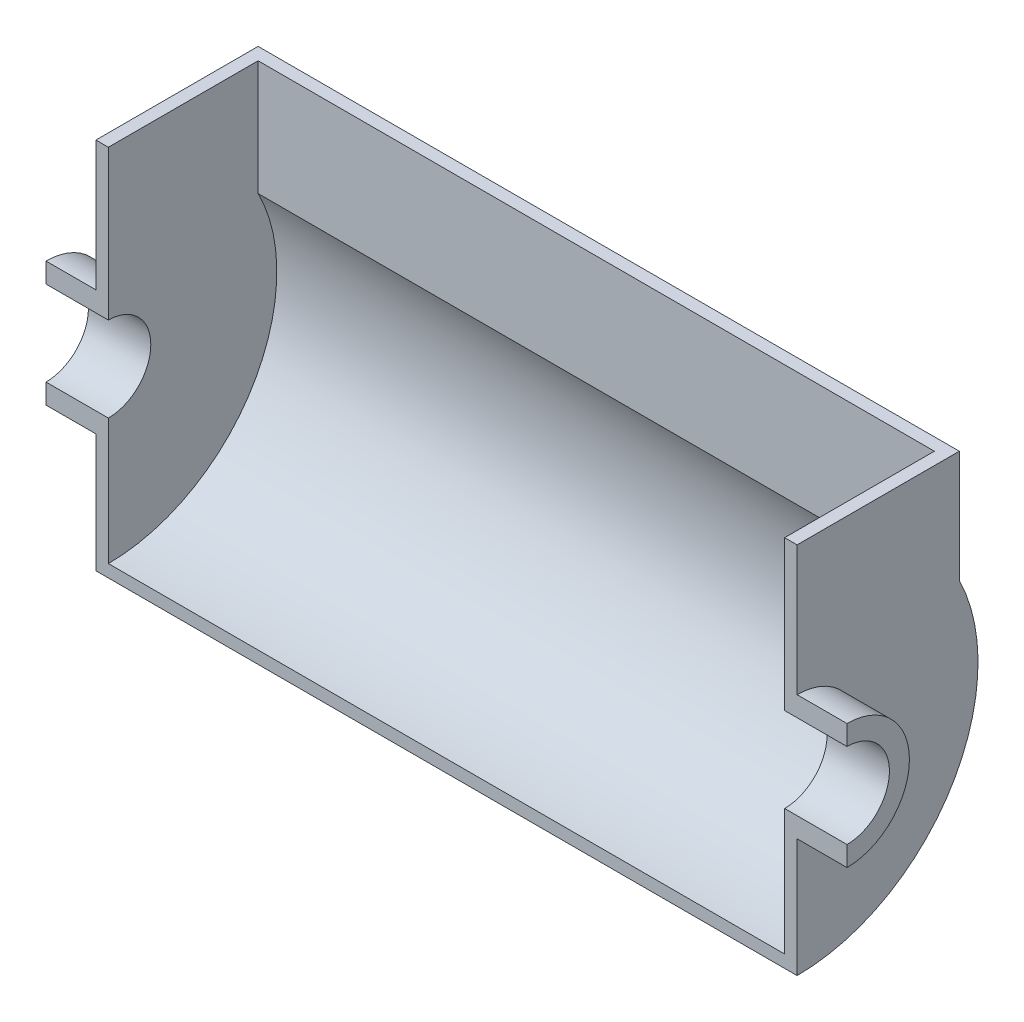
from build123d import *

# Parameters (mm, degrees)
BOSS_EXTRUDE1_DEPTH      = 20
BOSS_EXTRUDE1_DEPTH_BACK = 5
BOSS_EXTRUDE2_DEPTH      = 5
BOSS_EXTRUDE3_DEPTH      = 271
BOSS_EXTRUDE4_DEPTH      = 5
BOSS_EXTRUDE5_START      = 25
BOSS_EXTRUDE5_DEPTH      = 25


with BuildPart() as part:
    # Sketch1 → Boss-Extrude1 (new, two sides: drawn at the far end of the back side and taken through both)
    with BuildSketch(Plane(origin=(0, 0, 0), x_dir=(0, 0, -1), z_dir=(1, 0, 0)).offset(-BOSS_EXTRUDE1_DEPTH_BACK)):
        with BuildLine():
            Line((0, -25), (0, -17))
            ThreePointArc((0, -17), (17, 0), (0, 17))
            Line((0, 17), (0, 25))
            ThreePointArc((0, 25), (25, 0), (0, -25))
        make_face()
    extrude(amount=BOSS_EXTRUDE1_DEPTH + BOSS_EXTRUDE1_DEPTH_BACK)



with BuildPart() as body_2:
    # Sketch1_3 → Boss-Extrude2 (new body)
    with BuildSketch(Plane(origin=(0, 0, 0), x_dir=(0, 0, -1), z_dir=(1, 0, 0))):
        with BuildLine():
            ThreePointArc((0, 25), (25, 0), (0, -25))
            Line((0, -25), (0, -72.5))
            ThreePointArc((0, -72.5), (61.581037686, -38.262590053), (65, 32.113081447))
            Line((65, 32.113081447), (65, 77))
            Line((65, 77), (0, 77))
            Line((0, 77), (0, 25))
        make_face()
    extrude(amount=-BOSS_EXTRUDE2_DEPTH)


with BuildPart() as part_1:
    add(part.part)

    add(body_2.part)  # Boss-Extrude3 merges body 2
    # Sketch3 → Boss-Extrude3 (add)
    with BuildSketch(Plane.ZY.offset(5)):
        with BuildLine():
            Line((-60, 77), (-60, 30.923292192))
            ThreePointArc((-60, 30.923292192), (-57.634938288, -35.134938288), (0, -67.5))
            Line((0, -67.5), (0, -72.5))
            ThreePointArc((0, -72.5), (-61.581037686, -38.262590053), (-65, 32.113081447))
            Line((-65, 32.113081447), (-65, 77))
            Line((-65, 77), (-60, 77))
        make_face()
    extrude(amount=BOSS_EXTRUDE3_DEPTH)

    # Sketch5 → Boss-Extrude4 (add)
    with BuildSketch(Plane.ZY.offset(276)):
        with BuildLine():
            ThreePointArc((-65, 32.113081447), (-61.581037686, -38.262590053), (0, -72.5))
            Line((0, -72.5), (0, -25))
            ThreePointArc((0, -25), (-25, 0), (0, 25))
            Line((0, 25), (0, 77))
            Line((0, 77), (-65, 77))
            Line((-65, 77), (-65, 32.113081447))
        make_face()
    extrude(amount=BOSS_EXTRUDE4_DEPTH)

    # Sketch5_4 → Boss-Extrude5 (add)
    with BuildSketch(Plane.ZY.offset(276).offset(BOSS_EXTRUDE5_START)):
        with BuildLine():
            ThreePointArc((0, 25), (-25, 0), (0, -25))
            Line((0, -25), (0, -17))
            ThreePointArc((0, -17), (-17, 0), (0, 17))
            Line((0, 17), (0, 25))
        make_face()
    extrude(amount=-BOSS_EXTRUDE5_DEPTH)


solid = part_1.part
